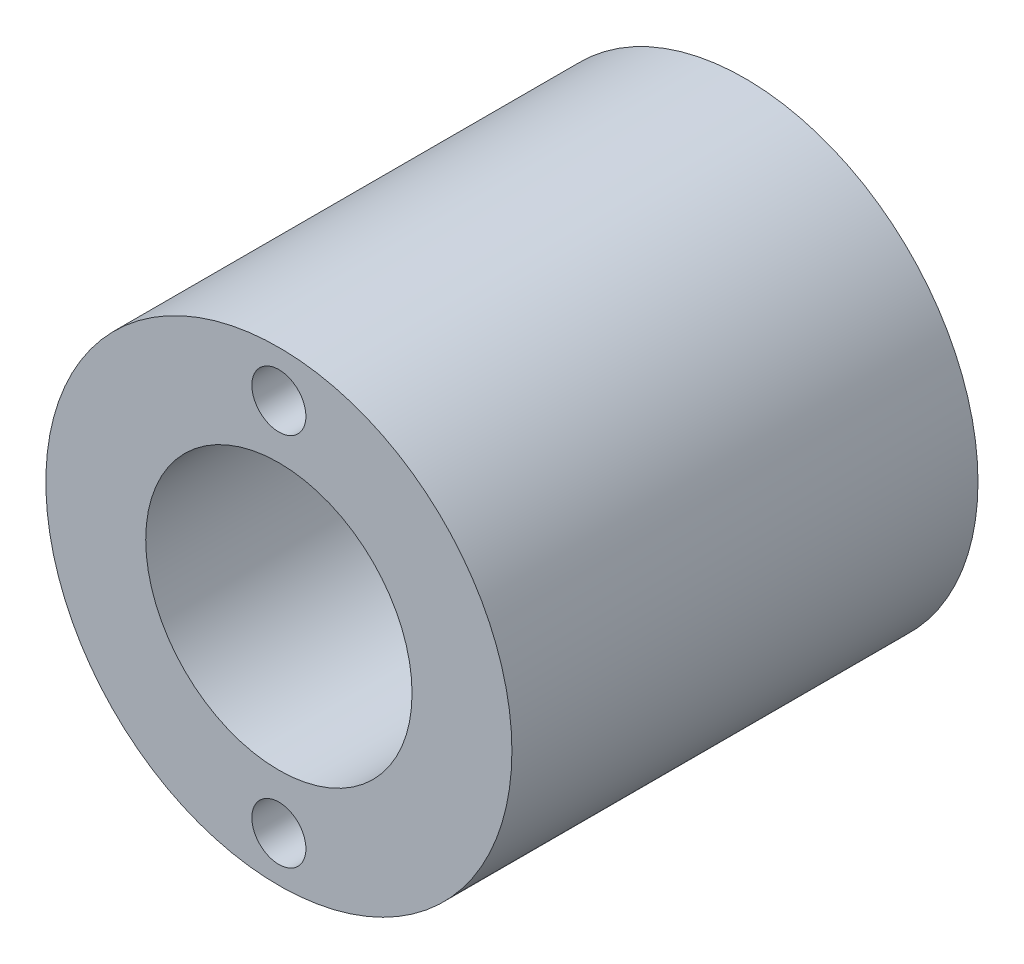
from build123d import *

# Parameters (mm, degrees)
SKETCH1_R           = 22.225
SKETCH1_R_2         = 12.7
SKETCH1_R_3         = 2.5781
BOSS_EXTRUDE1_DEPTH = 44.45
SKETCH2_R           = 6.35
CUT_EXTRUDE1_DEPTH  = 44.45


with BuildPart() as part:
    # Sketch1 → Boss-Extrude1 (new body)
    with BuildSketch(Plane.XY):
        Circle(SKETCH1_R)
        Circle(SKETCH1_R_2, mode=Mode.SUBTRACT)
        with Locations((0, 17.81175)):
            Circle(SKETCH1_R_3, mode=Mode.SUBTRACT)
        with Locations((0, -17.907)):
            Circle(SKETCH1_R_3, mode=Mode.SUBTRACT)
    extrude(amount=BOSS_EXTRUDE1_DEPTH)

    # Sketch2 → Cut-Extrude1 (cut)
    with BuildSketch(Plane(origin=(0, 0, 0), x_dir=(0, 0, -1), z_dir=(1, 0, 0))):
        with Locations((-8.89, 0)):
            Circle(SKETCH2_R)
    extrude(amount=-CUT_EXTRUDE1_DEPTH, mode=Mode.SUBTRACT)


solid = part.part
